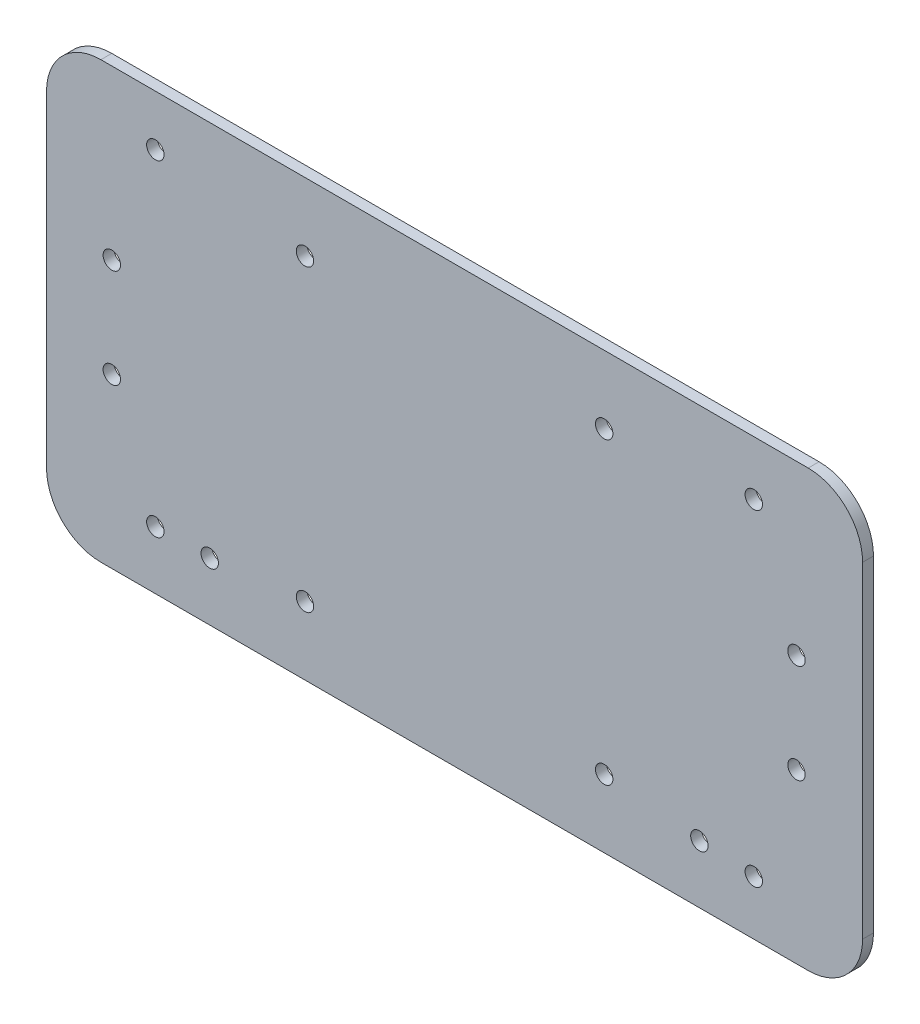
from build123d import *

# Parameters (mm, degrees)
SKETCH1_R           = 1.6
BOSS_EXTRUDE1_DEPTH = 2


with BuildPart() as part:
    # Sketch1 → Boss-Extrude1 (new body)
    with BuildSketch(Plane.XY):
        with BuildLine():
            Line((-65, -40), (65, -40))
            ThreePointArc((65, -40), (72.071067812, -37.071067812), (75, -30))
            Line((75, -30), (75, 30))
            ThreePointArc((75, 30), (72.071067812, 37.071067812), (65, 40))
            Line((65, 40), (-65, 40))
            ThreePointArc((-65, 40), (-72.071067812, 37.071067812), (-75, 30))
            Line((-75, 30), (-75, -30))
            ThreePointArc((-75, -30), (-72.071067812, -37.071067812), (-65, -40))
        make_face()
        with Locations((-63, 9.1)):
            Circle(SKETCH1_R, mode=Mode.SUBTRACT)
        with Locations((-63, -9.1)):
            Circle(SKETCH1_R, mode=Mode.SUBTRACT)
        with Locations((62.85, 9.1)):
            Circle(SKETCH1_R, mode=Mode.SUBTRACT)
        with Locations((62.85, -9.1)):
            Circle(SKETCH1_R, mode=Mode.SUBTRACT)
        with Locations((55, 30)):
            Circle(SKETCH1_R, mode=Mode.SUBTRACT)
        with Locations((55, -30)):
            Circle(SKETCH1_R, mode=Mode.SUBTRACT)
        with Locations((-55, -29.333333333)):
            Circle(SKETCH1_R, mode=Mode.SUBTRACT)
        with Locations((-55, 30.666666667)):
            Circle(SKETCH1_R, mode=Mode.SUBTRACT)
        with Locations((-45, -29.333333333)):
            Circle(SKETCH1_R, mode=Mode.SUBTRACT)
        with Locations((45, -29.333333333)):
            Circle(SKETCH1_R, mode=Mode.SUBTRACT)
        with Locations((-27.5, -27.5)):
            Circle(SKETCH1_R, mode=Mode.SUBTRACT)
        with Locations((27.5, -27.5)):
            Circle(SKETCH1_R, mode=Mode.SUBTRACT)
        with Locations((-27.5, 27.5)):
            Circle(SKETCH1_R, mode=Mode.SUBTRACT)
        with Locations((27.5, 27.5)):
            Circle(SKETCH1_R, mode=Mode.SUBTRACT)
    extrude(amount=BOSS_EXTRUDE1_DEPTH)


solid = part.part
